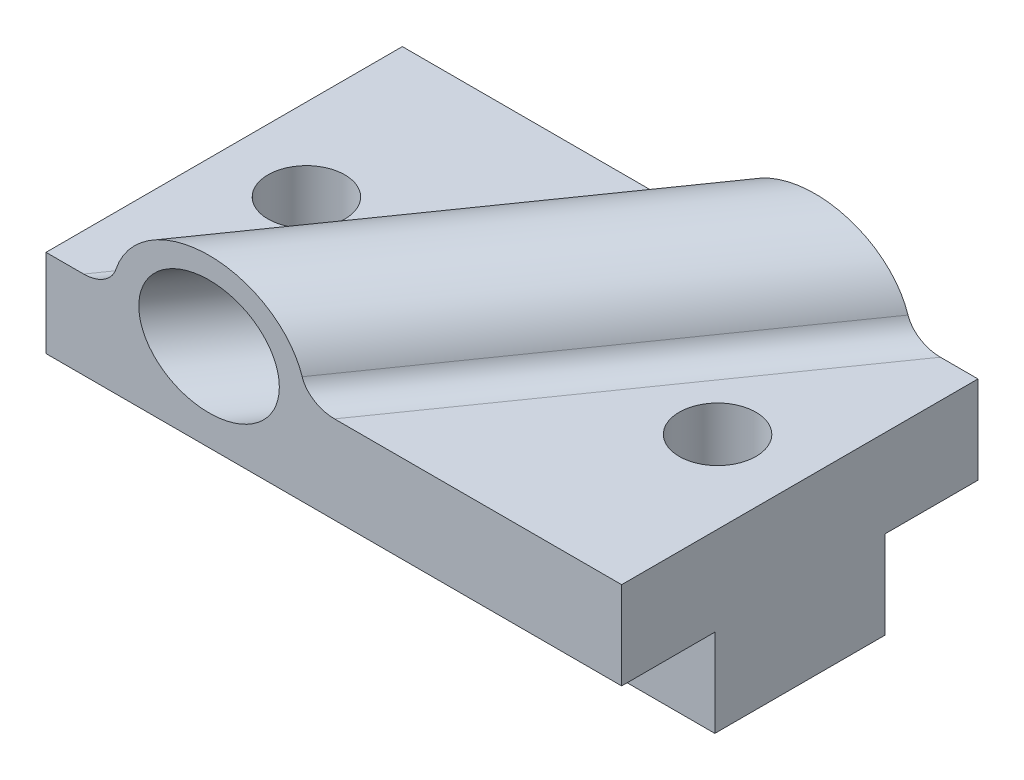
from build123d import *

# Parameters (mm, degrees)
BOSS_EXTRUDE1_DEPTH     = 52.5
SKETCH2_R               = 7
CUT_EXTRUDE1_DEPTH      = 105
BOSS_EXTRUDE2_REACH     = 90.389
SKETCH5_R               = 14.397777867
BOSS_EXTRUDE3_REACH     = 90.389
SKETCH5_2_R             = 14.397777867
CUT_EXTRUDE2_DEPTH      = 75
CUT_EXTRUDE2_DEPTH_BACK = 116
SKETCH7_R               = 10.5
FILLET1_R               = 5


with BuildPart() as part:
    # Sketch1 → Boss-Extrude1 (new, symmetric)
    with BuildSketch(Plane(origin=(0, 0, 0), x_dir=(0, 0, -1), z_dir=(1, 0, 0))):
        Polygon((-32.5, 0), (32.5, 0), (32.5, -16), (15.5, -16), (15.5, -32), (-15.5, -32), (-15.5, -16), (-32.5, -16), align=None)
    extrude(amount=BOSS_EXTRUDE1_DEPTH, both=True)

    # Sketch2 → Cut-Extrude1 (cut)
    with BuildSketch(Plane(origin=(0, 0, 0), x_dir=(1, 0, 0), z_dir=(0, 1, 0))):
        with Locations((37.5, 0)):
            Circle(SKETCH2_R)
        with Locations((-37.5, 0)):
            Circle(SKETCH2_R)
    extrude(amount=-CUT_EXTRUDE1_DEPTH, mode=Mode.SUBTRACT)

    # Boss-Extrude2: up to this plane
    boss_extrude2_end = Plane(origin=(52.5, -16, 32.5), z_dir=(0, 0, -1))
    # Sketch5 → Boss-Extrude2 (add, up to the surface)
    with BuildSketch(Plane(origin=(0, 0, 0), x_dir=(0.8191520442889911, 0, 0.5735764363510472), z_dir=(-0.5735764363510472, 0, 0.8191520442889912)), mode=Mode.PRIVATE) as boss_extrude2_sk1:
        Circle(SKETCH5_R)
    boss_extrude2_tool1 = split(extrude(boss_extrude2_sk1.sketch, amount=BOSS_EXTRUDE2_REACH, mode=Mode.PRIVATE), bisect_by=boss_extrude2_end, keep=Keep.BOTH, mode=Mode.PRIVATE)
    add(boss_extrude2_tool1.solids().sort_by_distance((0, 0, 0))[0])

    # Boss-Extrude3: up to this plane
    boss_extrude3_end = Plane(origin=(52.5, 0, -32.5), z_dir=(0, 0, 1))
    # Sketch5_2 → Boss-Extrude3 (add, up to the surface)
    with BuildSketch(Plane(origin=(0, 0, 0), x_dir=(0.8191520442889911, 0, 0.5735764363510472), z_dir=(-0.5735764363510472, 0, 0.8191520442889912)), mode=Mode.PRIVATE) as boss_extrude3_sk1:
        Circle(SKETCH5_2_R)
    boss_extrude3_tool1 = split(extrude(boss_extrude3_sk1.sketch, amount=-BOSS_EXTRUDE3_REACH, mode=Mode.PRIVATE), bisect_by=boss_extrude3_end, keep=Keep.BOTH, mode=Mode.PRIVATE)
    add(boss_extrude3_tool1.solids().sort_by_distance((0, 0, 0))[0])

    # Sketch7 → Cut-Extrude2 (cut, two sides: drawn at the far end of the back side and taken through both)
    with BuildSketch(Plane(origin=(0, 0, 0), x_dir=(0.8191520442889911, 0, 0.5735764363510472), z_dir=(-0.5735764363510472, 0, 0.8191520442889912)).offset(-CUT_EXTRUDE2_DEPTH_BACK)):
        Circle(SKETCH7_R)
    extrude(amount=CUT_EXTRUDE2_DEPTH + CUT_EXTRUDE2_DEPTH_BACK, mode=Mode.SUBTRACT)

    # Fillet1
    fillet1_edges = [part.edges().sort_by_distance(p)[0] for p in [
        (-17.576441355, 0, 0),
        (17.576441355, 0, 0),
    ]]
    fillet(fillet1_edges, radius=FILLET1_R)


solid = part.part
